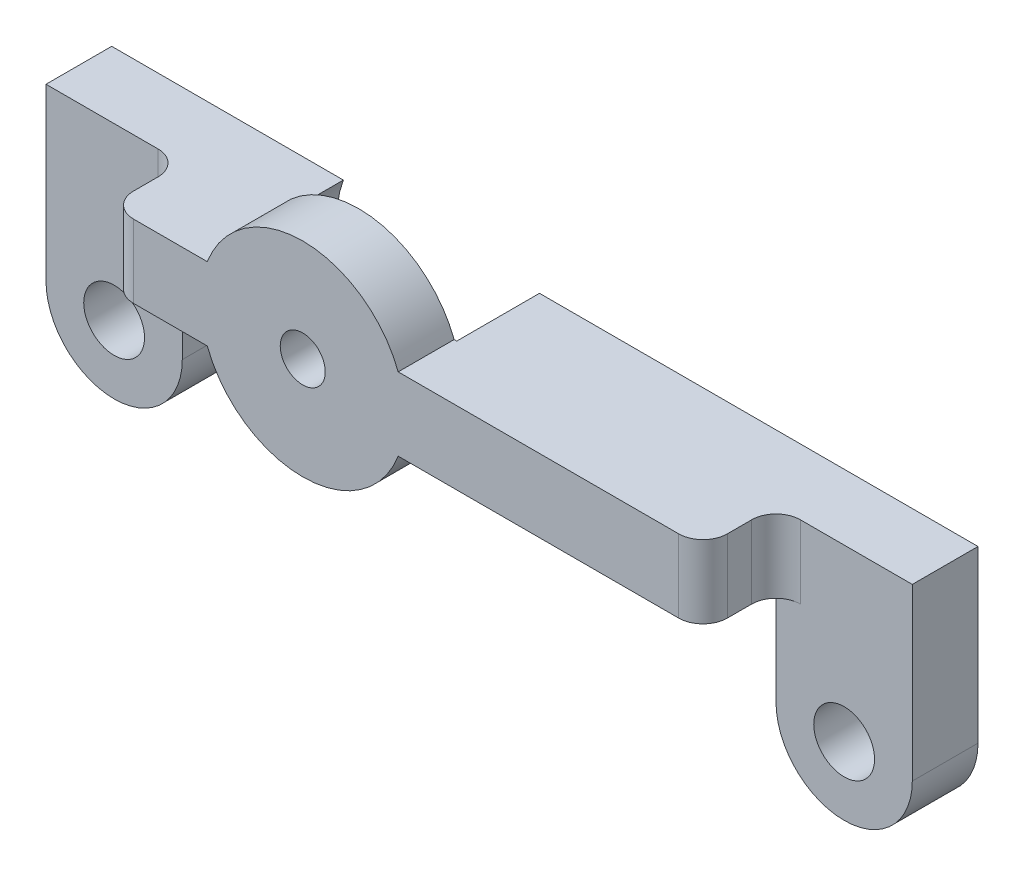
from build123d import *

# Parameters (mm, degrees)
SKETCH_1_R          = 1.25
SKETCH_1_R_2        = 0.925
EXTRUDE_1_DEPTH     = 7.7
SKETCH_2_R          = 4.3
CUT_EXTRUDE_1_DEPTH = 3.4
CUT_EXTRUDE_2_DEPTH = 5
CUT_EXTRUDE_3_DEPTH = 2
FILLET_2_R          = 1


with BuildPart() as part:
    # 草图1 → 凸台-拉伸1 (new body)
    with BuildSketch(Plane.XY):
        with BuildLine():
            Line((-8.173009049, 0.432285115), (-12.2, 0.432285115))
            Line((-12.2, 0.432285115), (-17.8, 0.432285115))
            Line((-17.8, 0.432285115), (-17.8, -6.567714885))
            ThreePointArc((-17.8, -6.567714885), (-15, -9.367714885), (-12.2, -6.567714885))
            Line((-12.2, -6.567714885), (-12.2, -3.067714885))
            Line((-12.2, -3.067714885), (-12.2, -2.567714885))
            Line((-12.2, -2.567714885), (-8.173009049, -2.567714885))
            ThreePointArc((-8.173009049, -2.567714885), (-4.25, -5.267714885), (-0.326990951, -2.567714885))
            Line((-0.326990951, -2.567714885), (12.2, -2.567714885))
            Line((12.2, -2.567714885), (12.2, -6.567714885))
            ThreePointArc((12.2, -6.567714885), (15, -9.367714885), (17.8, -6.567714885))
            Line((17.8, -6.567714885), (17.8, 0.432285115))
            Line((17.8, 0.432285115), (12.2, 0.432285115))
            Line((12.2, 0.432285115), (-0.326990951, 0.432285115))
            ThreePointArc((-0.326990951, 0.432285115), (-4.25, 3.132285115), (-8.173009049, 0.432285115))
        make_face()
        with Locations((-15, -6.567714885)):
            Circle(SKETCH_1_R, mode=Mode.SUBTRACT)
        with Locations((15, -6.567714885)):
            Circle(SKETCH_1_R, mode=Mode.SUBTRACT)
        with Locations((-4.25, -1.067714885)):
            Circle(SKETCH_1_R_2, mode=Mode.SUBTRACT)
        with BuildLine():
            Line((-8.173009049, 0.432285115), (-12.2, 0.432285115))
            Line((-12.2, 0.432285115), (-17.8, 0.432285115))
            Line((-17.8, 0.432285115), (-17.8, -6.567714885))
            ThreePointArc((-17.8, -6.567714885), (-15, -9.367714885), (-12.2, -6.567714885))
            Line((-12.2, -6.567714885), (-12.2, -3.067714885))
            Line((-12.2, -3.067714885), (-12.2, -2.567714885))
            Line((-12.2, -2.567714885), (-8.173009049, -2.567714885))
            ThreePointArc((-8.173009049, -2.567714885), (-4.25, -5.267714885), (-0.326990951, -2.567714885))
            Line((-0.326990951, -2.567714885), (12.2, -2.567714885))
            Line((12.2, -2.567714885), (12.2, -6.567714885))
            ThreePointArc((12.2, -6.567714885), (15, -9.367714885), (17.8, -6.567714885))
            Line((17.8, -6.567714885), (17.8, 0.432285115))
            Line((17.8, 0.432285115), (12.2, 0.432285115))
            Line((12.2, 0.432285115), (-0.326990951, 0.432285115))
            ThreePointArc((-0.326990951, 0.432285115), (-4.25, 3.132285115), (-8.173009049, 0.432285115))
        make_face()
        with Locations((-15, -6.567714885)):
            Circle(SKETCH_1_R, mode=Mode.SUBTRACT)
        with Locations((15, -6.567714885)):
            Circle(SKETCH_1_R, mode=Mode.SUBTRACT)
        with Locations((-4.25, -1.067714885)):
            Circle(SKETCH_1_R_2, mode=Mode.SUBTRACT)
    extrude(amount=EXTRUDE_1_DEPTH)

    # 草图2 → 切除-拉伸1 (cut)
    with BuildSketch(Plane(origin=(0, 0, 0), x_dir=(-1, 0, 0), z_dir=(0, 0, -1))):
        with Locations((4.25, -1.067714885)):
            Circle(SKETCH_2_R)
    extrude(amount=-CUT_EXTRUDE_1_DEPTH, mode=Mode.SUBTRACT)

    # 草图3 → 切除-拉伸2 (cut)
    with BuildSketch(Plane.XY.offset(7.7)):
        with BuildLine():
            Line((-17.8, 0.432285115), (-12.2, 0.432285115))
            Line((-12.2, 0.432285115), (-12.2, -6.567714885))
            ThreePointArc((-12.2, -6.567714885), (-15, -9.367714885), (-17.8, -6.567714885))
            Line((-17.8, -6.567714885), (-17.8, 0.432285115))
        make_face()
        with BuildLine():
            Line((12.2, 0.432285115), (17.8, 0.432285115))
            Line((17.8, 0.432285115), (17.8, -6.567714885))
            ThreePointArc((17.8, -6.567714885), (15, -9.367714885), (12.2, -6.567714885))
            Line((12.2, -6.567714885), (12.2, 0.432285115))
        make_face()
    extrude(amount=-CUT_EXTRUDE_2_DEPTH, mode=Mode.SUBTRACT)

    # 草图5 → 切除-拉伸3 (cut)
    with BuildSketch(Plane.XY.offset(7.7)):
        with BuildLine():
            Line((12.2, -2.567714885), (-0.326990951, -2.567714885))
            ThreePointArc((-0.326990951, -2.567714885), (-4.25, -5.267714885), (-8.173009049, -2.567714885))
            Line((-8.173009049, -2.567714885), (-12.2, -2.567714885))
            Line((-12.2, -2.567714885), (-12.2, 0.432285115))
            Line((-12.2, 0.432285115), (-8.173009049, 0.432285115))
            ThreePointArc((-8.173009049, 0.432285115), (-4.25, 3.132285115), (-0.326990951, 0.432285115))
            Line((-0.326990951, 0.432285115), (12.2, 0.432285115))
            Line((12.2, 0.432285115), (12.2, -2.567714885))
        make_face()
    extrude(amount=-CUT_EXTRUDE_3_DEPTH, mode=Mode.SUBTRACT)

    # 圆角2
    fillet_2_edges = [part.edges().sort_by_distance(p)[0] for p in [
        (12.2, -1.067714885, 5.7),
        (-12.2, -1.067714885, 5.7),
        (-12.2, -1.067714885, 2.7),
        (12.2, -1.067714885, 2.7),
    ]]
    fillet(fillet_2_edges, radius=FILLET_2_R)


solid = part.part
